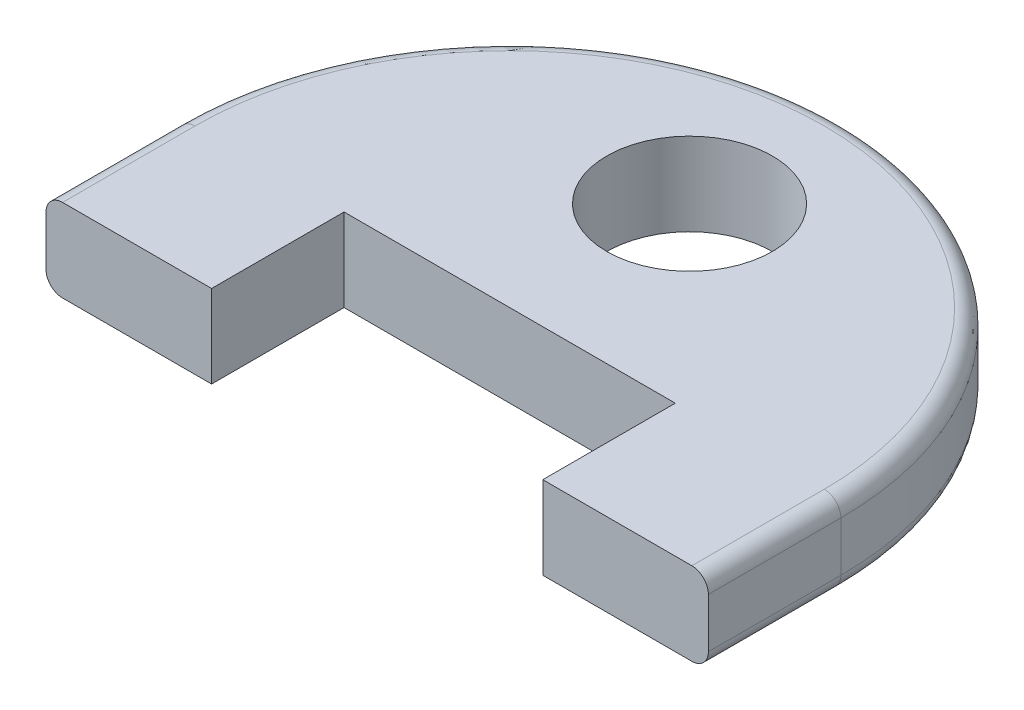
from build123d import *

# Parameters (mm, degrees)
BOSS_EXTRUDE1_DEPTH = 6.35
FILLET2_R           = 1.27
SKETCH2_R           = 6.35
CUT_EXTRUDE1_DEPTH  = 7.35


with BuildPart() as part:
    # Sketch1 → Boss-Extrude1 (new body)
    with BuildSketch(Plane(origin=(0, 0, 0), x_dir=(1, 0, 0), z_dir=(0, 1, 0))):
        with BuildLine():
            Line((-25.4, -10.16), (-12.7, -10.16))
            Line((-12.7, -10.16), (-12.7, 0))
            Line((-12.7, 0), (12.7, 0))
            Line((12.7, 0), (12.7, -10.16))
            Line((12.7, -10.16), (25.4, -10.16))
            Line((25.4, -10.16), (25.4, 0))
            ThreePointArc((25.4, 0), (0, 25.4), (-25.4, 0))
            Line((-25.4, 0), (-25.4, -10.16))
        make_face()
    extrude(amount=BOSS_EXTRUDE1_DEPTH)

    # Fillet2
    fillet2_edges = [part.edges().sort_by_distance(p)[0] for p in [
        (-25.4, 0, 5.08),
        (0, 0, -25.4),
        (25.4, 6.35, 5.08),
        (0, 6.35, -25.4),
        (-25.4, 6.35, 5.08),
        (25.4, 0, 5.08),
    ]]
    fillet(fillet2_edges, radius=FILLET2_R)

    # Sketch2 → Cut-Extrude1 (cut, through all)
    with BuildSketch(Plane(origin=(0, 6.35, 0), x_dir=(1, 0, 0), z_dir=(0, 1, 0))):
        with Locations((0, 13.796082309)):
            Circle(SKETCH2_R)
    extrude(amount=-CUT_EXTRUDE1_DEPTH, mode=Mode.SUBTRACT)


solid = part.part
